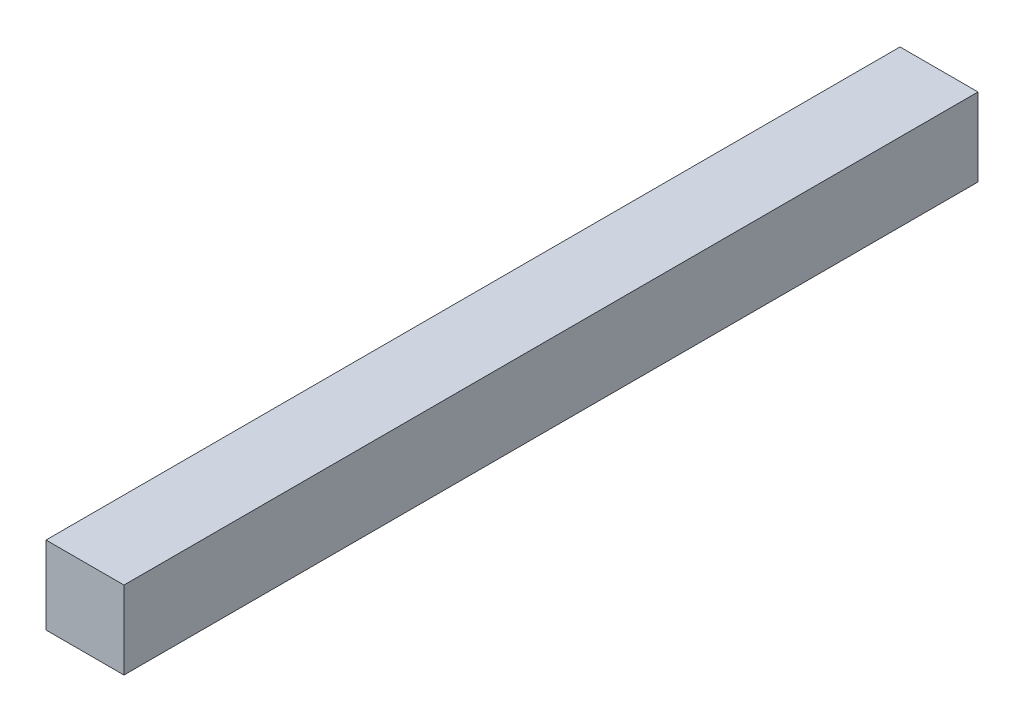
from build123d import *

# Parameters (mm, degrees)
SKETCH1_W           = 42
SKETCH1_H           = 42
BOSS_EXTRUDE1_DEPTH = 460


with BuildPart() as part:
    # Sketch1 → Boss-Extrude1 (new body)
    with BuildSketch(Plane.XY):
        Rectangle(SKETCH1_W, SKETCH1_H)
    extrude(amount=BOSS_EXTRUDE1_DEPTH)


solid = part.part
